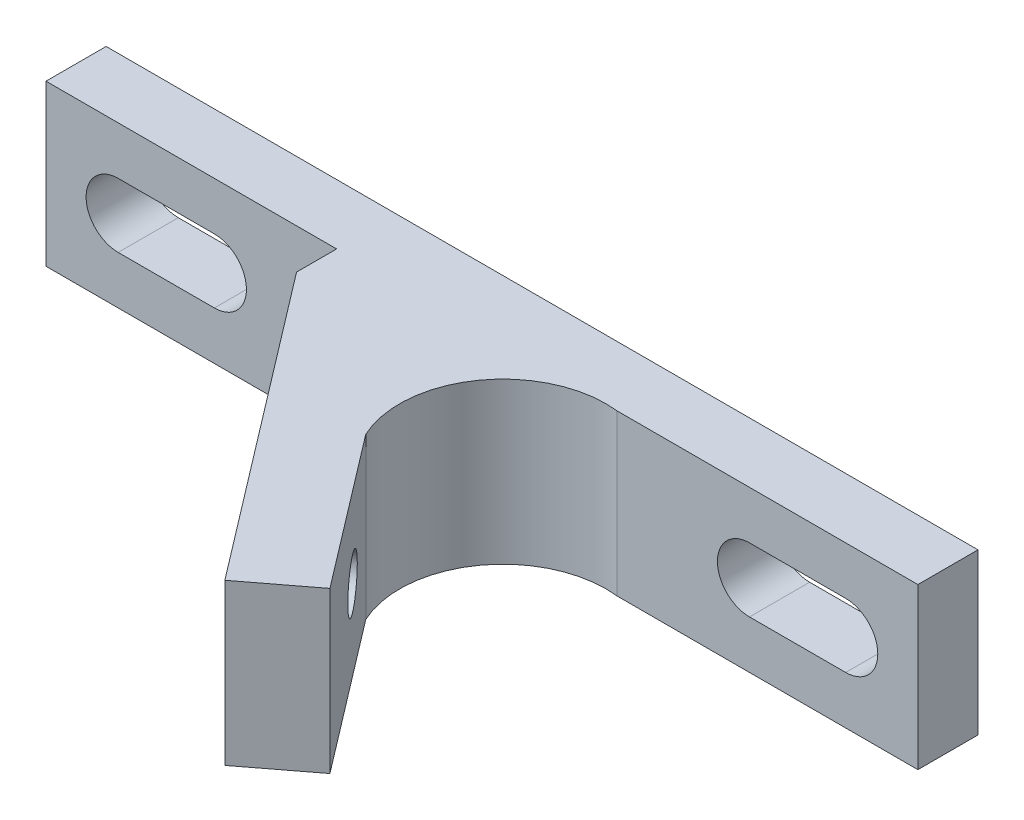
from build123d import *

# Parameters (mm, degrees)
EXTRUDE_1_DEPTH     = 8
CUT_EXTRUDE_1_REACH = 22.104
SKETCH_3_R          = 1.25
CUT_EXTRUDE_2_DEPTH = 6


with BuildPart() as part:
    # Эскиз1 → Бобышка-Вытянуть1 (new body)
    with BuildSketch(Plane(origin=(0, 0, 0), x_dir=(1, 0, 0), z_dir=(0, 1, 0))):
        with BuildLine():
            Line((-21.75, 0), (21.75, 0))
            Line((21.75, 0), (21.75, -3))
            Line((21.75, -3), (6.75, -3))
            ThreePointArc((6.75, -3), (1.985016763, -5.099789535), (1.486609174, -10.283009694))
            Line((1.486609174, -10.283009694), (7.25, -17.835050888))
            Line((7.25, -17.835050888), (4.276781652, -20.104082387))
            Line((4.276781652, -20.104082387), (-7.25, -5))
            Line((-7.25, -5), (-7.25, -3))
            Line((-7.25, -3), (-21.75, -3))
            Line((-21.75, -3), (-21.75, 0))
        make_face()
    extrude(amount=EXTRUDE_1_DEPTH)

    # Эскиз2 → Вырез-Вытянуть1 (cut, up to next)
    with BuildSketch(Plane(origin=(0, 0, 0), x_dir=(-1, 0, 0), z_dir=(0, 0, -1)), mode=Mode.PRIVATE) as cut_extrude_1_sk1:
        with BuildLine():
            Line((-18.15, 5.6), (-13.35, 5.6))
            ThreePointArc((-13.35, 5.6), (-11.75, 4), (-13.35, 2.4))
            Line((-13.35, 2.4), (-18.15, 2.4))
            ThreePointArc((-18.15, 2.4), (-19.75, 4), (-18.15, 5.6))
        make_face()
    cut_extrude_1_tool1 = extrude(cut_extrude_1_sk1.sketch, amount=-CUT_EXTRUDE_1_REACH, mode=Mode.PRIVATE) & part.part
    add(cut_extrude_1_tool1.solids().sort_by_distance((15.75, 4, 0))[0], mode=Mode.SUBTRACT)
    # Эскиз2 → Вырез-Вытянуть1 (cut, up to next)
    with BuildSketch(Plane(origin=(0, 0, 0), x_dir=(-1, 0, 0), z_dir=(0, 0, -1)), mode=Mode.PRIVATE) as cut_extrude_1_sk2:
        with BuildLine():
            Line((18.15, 5.6), (13.35, 5.6))
            ThreePointArc((13.35, 5.6), (11.75, 4), (13.35, 2.4))
            Line((13.35, 2.4), (18.15, 2.4))
            ThreePointArc((18.15, 2.4), (19.75, 4), (18.15, 5.6))
        make_face()
    cut_extrude_1_tool2 = extrude(cut_extrude_1_sk2.sketch, amount=-CUT_EXTRUDE_1_REACH, mode=Mode.PRIVATE) & part.part
    add(cut_extrude_1_tool2.solids().sort_by_distance((-15.75, 4, 0))[0], mode=Mode.SUBTRACT)

    # Эскиз3 → Вырез-Вытянуть2 (cut)
    with BuildSketch(Plane(origin=(-6.9930021, 0, 5.336756397), x_dir=(0.606672719, 0, 0.794951705), z_dir=(-0.794951705, 0, 0.606672719))):
        with Locations((12.576381314, 4)):
            Circle(SKETCH_3_R)
        with Locations((3.076381314, 4)):
            Circle(SKETCH_3_R)
    extrude(amount=-CUT_EXTRUDE_2_DEPTH, mode=Mode.SUBTRACT)


solid = part.part
